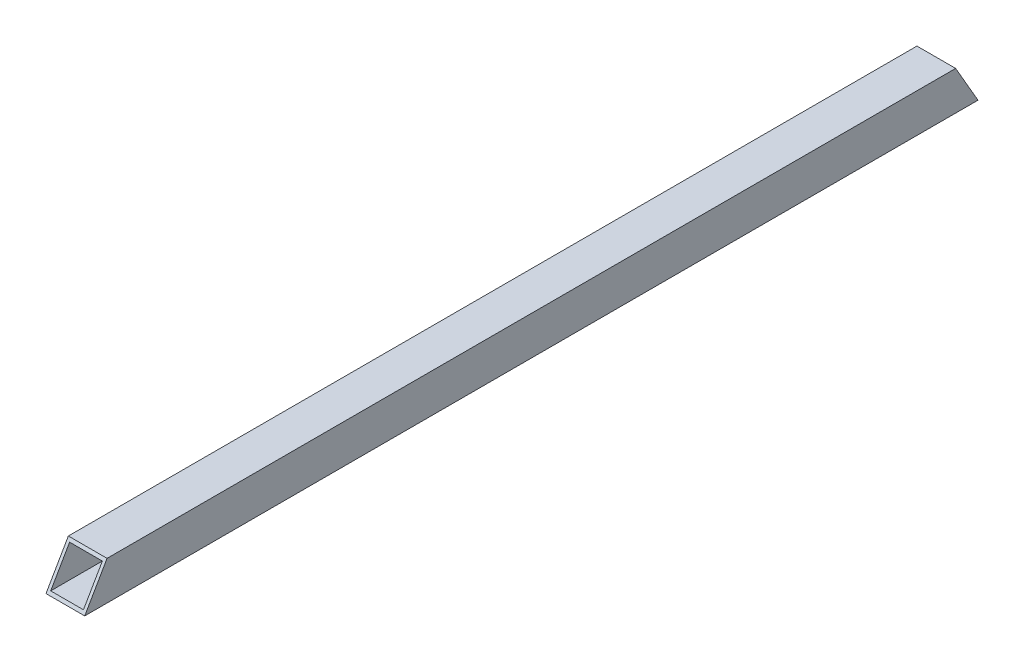
from build123d import *

# Parameters (mm, degrees)
SKETCH1_W               = 13
SKETCH1_H               = 13
SKETCH1_W_2             = 11
SKETCH1_H_2             = 11
BOSS_EXTRUDE1_DEPTH     = 300
CUT_EXTRUDE2_DEPTH      = 1
CUT_EXTRUDE2_DEPTH_BACK = 14
CUT_EXTRUDE3_DEPTH      = 1
CUT_EXTRUDE3_DEPTH_BACK = 14


with BuildPart() as part:
    # Sketch1 → Boss-Extrude1 (new body)
    with BuildSketch(Plane.XY):
        Rectangle(SKETCH1_W, SKETCH1_H)
        Rectangle(SKETCH1_W_2, SKETCH1_H_2, mode=Mode.SUBTRACT)
    extrude(amount=BOSS_EXTRUDE1_DEPTH)

    # Sketch2 → Cut-Extrude2 (cut, two sides)
    with BuildSketch(Plane(origin=(6.5, 0, 0), x_dir=(0, 0, -1), z_dir=(1, 0, 0))) as cut_extrude2_sk:
        Polygon((12.787088063, 535.263128477), (-292.494446501, 6.5), (-300, -6.5), (-605.281534564, -535.263128477), (-1662.807791518, 75.299940651), (-1044.739168891, 1145.826197605), align=None)
    extrude(amount=CUT_EXTRUDE2_DEPTH, mode=Mode.SUBTRACT)
    extrude(cut_extrude2_sk.sketch, amount=-CUT_EXTRUDE2_DEPTH_BACK, mode=Mode.SUBTRACT)

    # Sketch3 → Cut-Extrude3 (cut, two sides)
    with BuildSketch(Plane(origin=(6.5, 0, 0), x_dir=(0, 0, -1), z_dir=(1, 0, 0))) as cut_extrude3_sk:
        Polygon((305.281534564, -535.263128477), (0, -6.5), (-7.505553499, 6.5), (-312.787088063, 535.263128477), (744.739168891, 1145.826197605), (1362.807791518, 75.299940651), align=None)
    extrude(amount=CUT_EXTRUDE3_DEPTH, mode=Mode.SUBTRACT)
    extrude(cut_extrude3_sk.sketch, amount=-CUT_EXTRUDE3_DEPTH_BACK, mode=Mode.SUBTRACT)


solid = part.part
